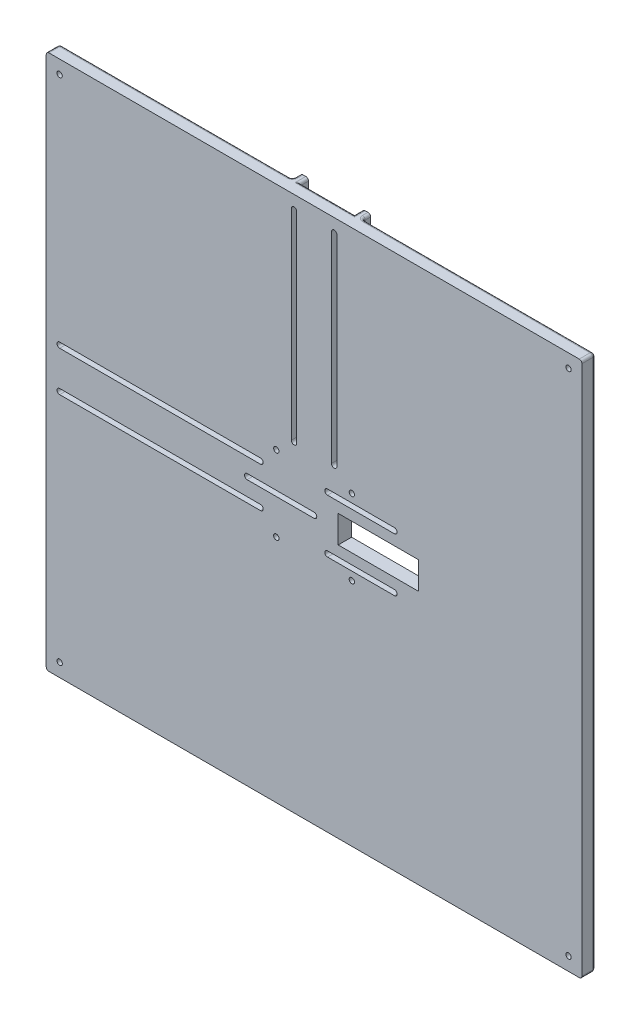
from build123d import *

# Parameters (mm, degrees)
ESQUISSE1_W             = 200
ESQUISSE1_H             = 200
BOSS_EXTRU_1_DEPTH      = 5
ESQUISSE2_W             = 80
ESQUISSE2_H             = 3
ESQUISSE2_W_2           = 3
ESQUISSE2_H_2           = 80
BOSS_EXTRU_2_DEPTH      = 3
CONG_1_R                = 1
ENL_V_MAT_EXTRU_1_REACH = 7
ESQUISSE4_R             = 1
ENL_V_MAT_EXTRU_2_DEPTH = 6
ENL_V_MAT_EXTRU_3_REACH = 7
ENL_V_MAT_EXTRU_5_REACH = 10
ENL_V_MAT_EXTRU_7_REACH = 7
ESQUISSE11_W            = 30
ESQUISSE11_H            = 10.2
ESQUISSE12_W            = 31
ESQUISSE12_H            = 4.2
ENL_V_MAT_EXTRU_9_DEPTH = 2
CONG_2_R                = 0.5


with BuildPart() as part:
    # Esquisse1 → Boss.-Extru.1 (new body)
    with BuildSketch(Plane.XY):
        Rectangle(ESQUISSE1_W, ESQUISSE1_H)
    extrude(amount=BOSS_EXTRU_1_DEPTH)

    # Esquisse2 → Boss.-Extru.2 (add)
    with BuildSketch(Plane(origin=(0, 0, 0), x_dir=(-1, 0, 0), z_dir=(0, 0, -1))):
        with Locations((60, 11.6)):
            Rectangle(ESQUISSE2_W, ESQUISSE2_H)
        with Locations((60, -11.6)):
            Rectangle(ESQUISSE2_W, ESQUISSE2_H)
        with Locations((11.6, 60)):
            Rectangle(ESQUISSE2_W_2, ESQUISSE2_H_2)
        with Locations((-11.6, 60)):
            Rectangle(ESQUISSE2_W_2, ESQUISSE2_H_2)
    extrude(amount=BOSS_EXTRU_2_DEPTH)

    # Congé1
    cong_1_edges = [part.edges().sort_by_distance(p)[0] for p in [
        (-100, 0, 0),
        (-60, 13.1, 0),
        (-100, 13.1, -1.5),
        (-20, 11.6, 0),
        (-20, 13.1, -1.5),
        (-100, 10.1, -1.5),
        (-100, -56.55, 0),
        (-100, -13.1, -1.5),
        (-100, -10.1, -1.5),
        (-20, -11.6, 0),
        (-60, -13.1, 0),
        (-20, -13.1, -1.5),
        (-56.55, 100, 0),
        (-11.6, 20, 0),
        (-13.1, 60, 0),
        (-13.1, 20, -1.5),
        (-13.1, 100, -1.5),
        (-10.1, 100, -1.5),
        (56.55, 100, 0),
        (100, 0, 0),
        (0, -100, 0),
        (-100, 56.55, 0),
        (-100, 100, 2.5),
        (100, 100, 2.5),
        (100, -100, 2.5),
        (-100, -100, 2.5),
        (0, 100, 0),
        (11.6, 20, 0),
        (13.1, 20, -1.5),
        (10.1, 100, -1.5),
        (13.1, 60, 0),
        (13.1, 100, -1.5),
    ]]
    fillet(cong_1_edges, radius=CONG_1_R)

    # Esquisse4 → Enlèv. mat.-Extru.1 (cut, up to next)
    with BuildSketch(Plane(origin=(0, 0, 0), x_dir=(-1, 0, 0), z_dir=(0, 0, -1)), mode=Mode.PRIVATE) as enl_v_mat_extru_1_sk1:
        with Locations((-14.1, 14.1)):
            Circle(ESQUISSE4_R)
    enl_v_mat_extru_1_tool1 = extrude(enl_v_mat_extru_1_sk1.sketch, amount=-ENL_V_MAT_EXTRU_1_REACH, mode=Mode.PRIVATE) & part.part
    add(enl_v_mat_extru_1_tool1.solids().sort_by_distance((14.1, 14.1, 0))[0], mode=Mode.SUBTRACT)
    # Esquisse4 → Enlèv. mat.-Extru.1 (cut, up to next)
    with BuildSketch(Plane(origin=(0, 0, 0), x_dir=(-1, 0, 0), z_dir=(0, 0, -1)), mode=Mode.PRIVATE) as enl_v_mat_extru_1_sk2:
        with Locations((14.1, 14.1)):
            Circle(ESQUISSE4_R)
    enl_v_mat_extru_1_tool2 = extrude(enl_v_mat_extru_1_sk2.sketch, amount=-ENL_V_MAT_EXTRU_1_REACH, mode=Mode.PRIVATE) & part.part
    add(enl_v_mat_extru_1_tool2.solids().sort_by_distance((-14.1, 14.1, 0))[0], mode=Mode.SUBTRACT)
    # Esquisse4 → Enlèv. mat.-Extru.1 (cut, up to next)
    with BuildSketch(Plane(origin=(0, 0, 0), x_dir=(-1, 0, 0), z_dir=(0, 0, -1)), mode=Mode.PRIVATE) as enl_v_mat_extru_1_sk3:
        with Locations((14.1, -14.1)):
            Circle(ESQUISSE4_R)
    enl_v_mat_extru_1_tool3 = extrude(enl_v_mat_extru_1_sk3.sketch, amount=-ENL_V_MAT_EXTRU_1_REACH, mode=Mode.PRIVATE) & part.part
    add(enl_v_mat_extru_1_tool3.solids().sort_by_distance((-14.1, -14.1, 0))[0], mode=Mode.SUBTRACT)
    # Esquisse4 → Enlèv. mat.-Extru.1 (cut, up to next)
    with BuildSketch(Plane(origin=(0, 0, 0), x_dir=(-1, 0, 0), z_dir=(0, 0, -1)), mode=Mode.PRIVATE) as enl_v_mat_extru_1_sk4:
        with Locations((-14.1, -14.1)):
            Circle(ESQUISSE4_R)
    enl_v_mat_extru_1_tool4 = extrude(enl_v_mat_extru_1_sk4.sketch, amount=-ENL_V_MAT_EXTRU_1_REACH, mode=Mode.PRIVATE) & part.part
    add(enl_v_mat_extru_1_tool4.solids().sort_by_distance((14.1, -14.1, 0))[0], mode=Mode.SUBTRACT)
    # Esquisse4 → Enlèv. mat.-Extru.1 (cut, up to next)
    with BuildSketch(Plane(origin=(0, 0, 0), x_dir=(-1, 0, 0), z_dir=(0, 0, -1)), mode=Mode.PRIVATE) as enl_v_mat_extru_1_sk5:
        with Locations((-95, -95)):
            Circle(ESQUISSE4_R)
    enl_v_mat_extru_1_tool5 = extrude(enl_v_mat_extru_1_sk5.sketch, amount=-ENL_V_MAT_EXTRU_1_REACH, mode=Mode.PRIVATE) & part.part
    add(enl_v_mat_extru_1_tool5.solids().sort_by_distance((95, -95, 0))[0], mode=Mode.SUBTRACT)
    # Esquisse4 → Enlèv. mat.-Extru.1 (cut, up to next)
    with BuildSketch(Plane(origin=(0, 0, 0), x_dir=(-1, 0, 0), z_dir=(0, 0, -1)), mode=Mode.PRIVATE) as enl_v_mat_extru_1_sk6:
        with Locations((-95, 95)):
            Circle(ESQUISSE4_R)
    enl_v_mat_extru_1_tool6 = extrude(enl_v_mat_extru_1_sk6.sketch, amount=-ENL_V_MAT_EXTRU_1_REACH, mode=Mode.PRIVATE) & part.part
    add(enl_v_mat_extru_1_tool6.solids().sort_by_distance((95, 95, 0))[0], mode=Mode.SUBTRACT)
    # Esquisse4 → Enlèv. mat.-Extru.1 (cut, up to next)
    with BuildSketch(Plane(origin=(0, 0, 0), x_dir=(-1, 0, 0), z_dir=(0, 0, -1)), mode=Mode.PRIVATE) as enl_v_mat_extru_1_sk7:
        with Locations((95, -95)):
            Circle(ESQUISSE4_R)
    enl_v_mat_extru_1_tool7 = extrude(enl_v_mat_extru_1_sk7.sketch, amount=-ENL_V_MAT_EXTRU_1_REACH, mode=Mode.PRIVATE) & part.part
    add(enl_v_mat_extru_1_tool7.solids().sort_by_distance((-95, -95, 0))[0], mode=Mode.SUBTRACT)
    # Esquisse4 → Enlèv. mat.-Extru.1 (cut, up to next)
    with BuildSketch(Plane(origin=(0, 0, 0), x_dir=(-1, 0, 0), z_dir=(0, 0, -1)), mode=Mode.PRIVATE) as enl_v_mat_extru_1_sk8:
        with Locations((95, 95)):
            Circle(ESQUISSE4_R)
    enl_v_mat_extru_1_tool8 = extrude(enl_v_mat_extru_1_sk8.sketch, amount=-ENL_V_MAT_EXTRU_1_REACH, mode=Mode.PRIVATE) & part.part
    add(enl_v_mat_extru_1_tool8.solids().sort_by_distance((-95, 95, 0))[0], mode=Mode.SUBTRACT)

    # Esquisse5 → Enlèv. mat.-Extru.2 (cut, through all)
    with BuildSketch(Plane(origin=(0, 0, 0), x_dir=(-1, 0, 0), z_dir=(0, 0, -1))):
        with BuildLine():
            Line((-6.5, 95), (-6.5, 20))
            ThreePointArc((-6.5, 20), (-7.5, 19), (-8.5, 20))
            Line((-8.5, 20), (-8.5, 95))
            ThreePointArc((-8.5, 95), (-7.5, 96), (-6.5, 95))
        make_face()
        with BuildLine():
            Line((8.5, 95), (8.5, 20))
            ThreePointArc((8.5, 20), (7.5, 19), (6.5, 20))
            Line((6.5, 20), (6.5, 95))
            ThreePointArc((6.5, 95), (7.5, 96), (8.5, 95))
        make_face()
    extrude(amount=-ENL_V_MAT_EXTRU_2_DEPTH, mode=Mode.SUBTRACT)

    # Esquisse6 → Enlèv. mat.-Extru.3 (cut, up to next)
    with BuildSketch(Plane(origin=(0, 0, 0), x_dir=(-1, 0, 0), z_dir=(0, 0, -1)), mode=Mode.PRIVATE) as enl_v_mat_extru_3_sk1:
        with BuildLine():
            Line((95, -8.5), (20, -8.5))
            ThreePointArc((20, -8.5), (19, -7.5), (20, -6.5))
            Line((20, -6.5), (95, -6.5))
            ThreePointArc((95, -6.5), (96, -7.5), (95, -8.5))
        make_face()
    enl_v_mat_extru_3_tool1 = extrude(enl_v_mat_extru_3_sk1.sketch, amount=-ENL_V_MAT_EXTRU_3_REACH, mode=Mode.PRIVATE) & part.part
    add(enl_v_mat_extru_3_tool1.solids().sort_by_distance((-57.5, -7.5, 0))[0], mode=Mode.SUBTRACT)
    # Esquisse6 → Enlèv. mat.-Extru.3 (cut, up to next)
    with BuildSketch(Plane(origin=(0, 0, 0), x_dir=(-1, 0, 0), z_dir=(0, 0, -1)), mode=Mode.PRIVATE) as enl_v_mat_extru_3_sk2:
        with BuildLine():
            Line((20, 8.5), (95, 8.5))
            ThreePointArc((95, 8.5), (96, 7.5), (95, 6.5))
            Line((95, 6.5), (20, 6.5))
            ThreePointArc((20, 6.5), (19, 7.5), (20, 8.5))
        make_face()
    enl_v_mat_extru_3_tool2 = extrude(enl_v_mat_extru_3_sk2.sketch, amount=-ENL_V_MAT_EXTRU_3_REACH, mode=Mode.PRIVATE) & part.part
    add(enl_v_mat_extru_3_tool2.solids().sort_by_distance((-57.5, 7.5, 0))[0], mode=Mode.SUBTRACT)

    # Esquisse9 → Enlèv. mat.-Extru.5 (cut, up to next)
    with BuildSketch(Plane.XY.offset(5), mode=Mode.PRIVATE) as enl_v_mat_extru_5_sk1:
        with BuildLine():
            Line((-25, 1), (0, 1))
            ThreePointArc((0, 1), (1, 0), (0, -1))
            Line((0, -1), (-25, -1))
            ThreePointArc((-25, -1), (-26, 0), (-25, 1))
        make_face()
    enl_v_mat_extru_5_tool1 = extrude(enl_v_mat_extru_5_sk1.sketch, amount=-ENL_V_MAT_EXTRU_5_REACH, mode=Mode.PRIVATE) & part.part
    add(enl_v_mat_extru_5_tool1.solids().sort_by_distance((-12.5, 0, 5))[0], mode=Mode.SUBTRACT)
    # Esquisse9 → Enlèv. mat.-Extru.5 (cut, up to next)
    with BuildSketch(Plane.XY.offset(5), mode=Mode.PRIVATE) as enl_v_mat_extru_5_sk2:
        with BuildLine():
            Line((5, 11), (30, 11))
            ThreePointArc((30, 11), (31, 10), (30, 9))
            Line((30, 9), (5, 9))
            ThreePointArc((5, 9), (4, 10), (5, 11))
        make_face()
    enl_v_mat_extru_5_tool2 = extrude(enl_v_mat_extru_5_sk2.sketch, amount=-ENL_V_MAT_EXTRU_5_REACH, mode=Mode.PRIVATE) & part.part
    add(enl_v_mat_extru_5_tool2.solids().sort_by_distance((17.5, 10, 5))[0], mode=Mode.SUBTRACT)
    # Esquisse9 → Enlèv. mat.-Extru.5 (cut, up to next)
    with BuildSketch(Plane.XY.offset(5), mode=Mode.PRIVATE) as enl_v_mat_extru_5_sk3:
        with BuildLine():
            Line((5, -9), (30, -9))
            ThreePointArc((30, -9), (31, -10), (30, -11))
            Line((30, -11), (5, -11))
            ThreePointArc((5, -11), (4, -10), (5, -9))
        make_face()
    enl_v_mat_extru_5_tool3 = extrude(enl_v_mat_extru_5_sk3.sketch, amount=-ENL_V_MAT_EXTRU_5_REACH, mode=Mode.PRIVATE) & part.part
    add(enl_v_mat_extru_5_tool3.solids().sort_by_distance((17.5, -10, 5))[0], mode=Mode.SUBTRACT)

    # Esquisse11 → Enlèv. mat.-Extru.7 (cut, up to next)
    with BuildSketch(Plane(origin=(0, 0, 0), x_dir=(-1, 0, 0), z_dir=(0, 0, -1)), mode=Mode.PRIVATE) as enl_v_mat_extru_7_sk1:
        with Locations((-24, 0)):
            Rectangle(ESQUISSE11_W, ESQUISSE11_H)
    enl_v_mat_extru_7_tool1 = extrude(enl_v_mat_extru_7_sk1.sketch, amount=-ENL_V_MAT_EXTRU_7_REACH, mode=Mode.PRIVATE) & part.part
    add(enl_v_mat_extru_7_tool1.solids().sort_by_distance((24, 0, 0))[0], mode=Mode.SUBTRACT)

    # Esquisse12 → Enlèv. mat.-Extru.9 (cut)
    with BuildSketch(Plane(origin=(0, 0, 0), x_dir=(-1, 0, 0), z_dir=(0, 0, -1))):
        with Locations((-17.5, 10)):
            Rectangle(ESQUISSE12_W, ESQUISSE12_H)
        with Locations((-17.5, -10)):
            Rectangle(ESQUISSE12_W, ESQUISSE12_H)
        with Locations((12.5, 0)):
            Rectangle(ESQUISSE12_W, ESQUISSE12_H)
    extrude(amount=-ENL_V_MAT_EXTRU_9_DEPTH, mode=Mode.SUBTRACT)

    # Congé2
    cong_2_edges = [part.edges().sort_by_distance(p)[0] for p in [
        (33, 7.9, 1),
        (33, 12.1, 1),
        (2, 12.1, 1),
        (33, -12.1, 1),
        (33, -7.9, 1),
        (2, -7.9, 1),
        (2, -12.1, 1),
        (3, -2.1, 1),
        (3, 2.1, 1),
        (-28, 2.1, 1),
        (-28, -2.1, 1),
    ]]
    fillet(cong_2_edges, radius=CONG_2_R)


solid = part.part
